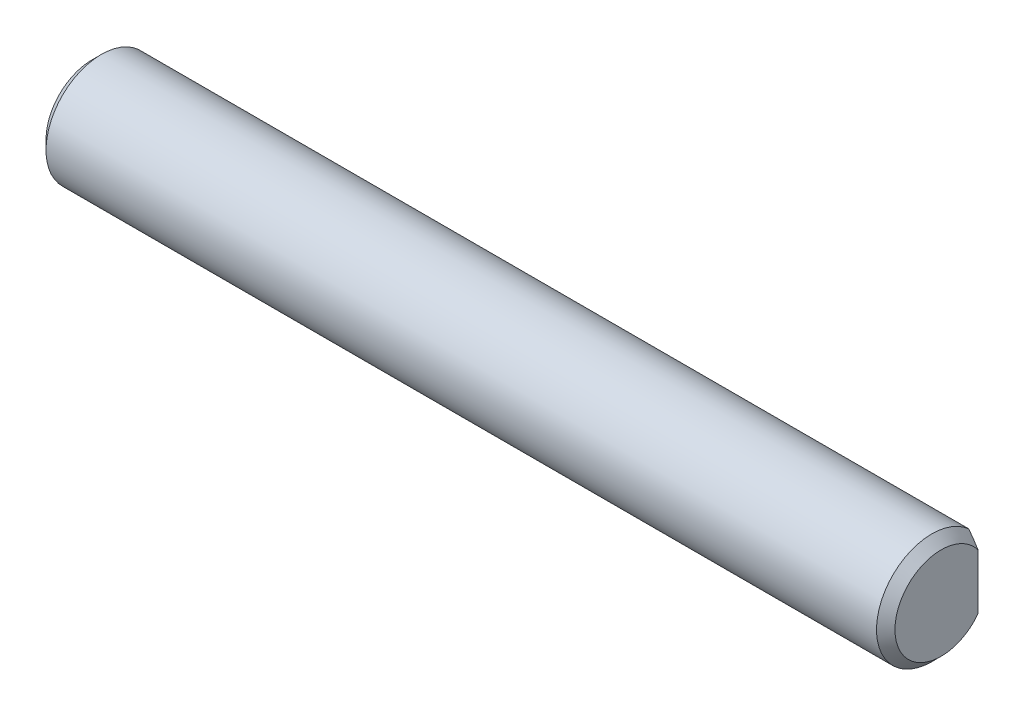
from build123d import *

# Parameters (mm, degrees)
SKETCH1_R           = 3
BOSS_EXTRUDE1_DEPTH = 46
CHAMFER1_SIZE       = 0.5
SKETCH2_W           = 1
SKETCH2_H           = 6
CUT_EXTRUDE1_DEPTH  = 6
CUT_EXTRUDE2_START  = -46
SKETCH2_3_W         = 1
SKETCH2_3_H         = 6
CUT_EXTRUDE2_DEPTH  = 6


with BuildPart() as part:
    # Sketch1 → Boss-Extrude1 (new body)
    with BuildSketch(Plane(origin=(0, 0, 0), x_dir=(0, 0, -1), z_dir=(1, 0, 0))):
        Circle(SKETCH1_R)
    extrude(amount=BOSS_EXTRUDE1_DEPTH)

    # Chamfer1
    chamfer1_edges = [part.edges().sort_by_distance(p)[0] for p in [
        (46, 0, 3),
        (0, 0, 3),
    ]]
    chamfer(chamfer1_edges, length=CHAMFER1_SIZE)

    # Sketch2 → Cut-Extrude1 (cut)
    with BuildSketch(Plane(origin=(46, 0, 0), x_dir=(0, 0, -1), z_dir=(1, 0, 0))):
        with Locations((2.5, 0)):
            Rectangle(SKETCH2_W, SKETCH2_H)
    extrude(amount=-CUT_EXTRUDE1_DEPTH, mode=Mode.SUBTRACT)

    # Sketch2_3 → Cut-Extrude2 (cut)
    with BuildSketch(Plane(origin=(46, 0, 0), x_dir=(0, 0, -1), z_dir=(1, 0, 0)).offset(CUT_EXTRUDE2_START)):
        with Locations((2.5, 0)):
            Rectangle(SKETCH2_3_W, SKETCH2_3_H)
    extrude(amount=CUT_EXTRUDE2_DEPTH, mode=Mode.SUBTRACT)


solid = part.part
